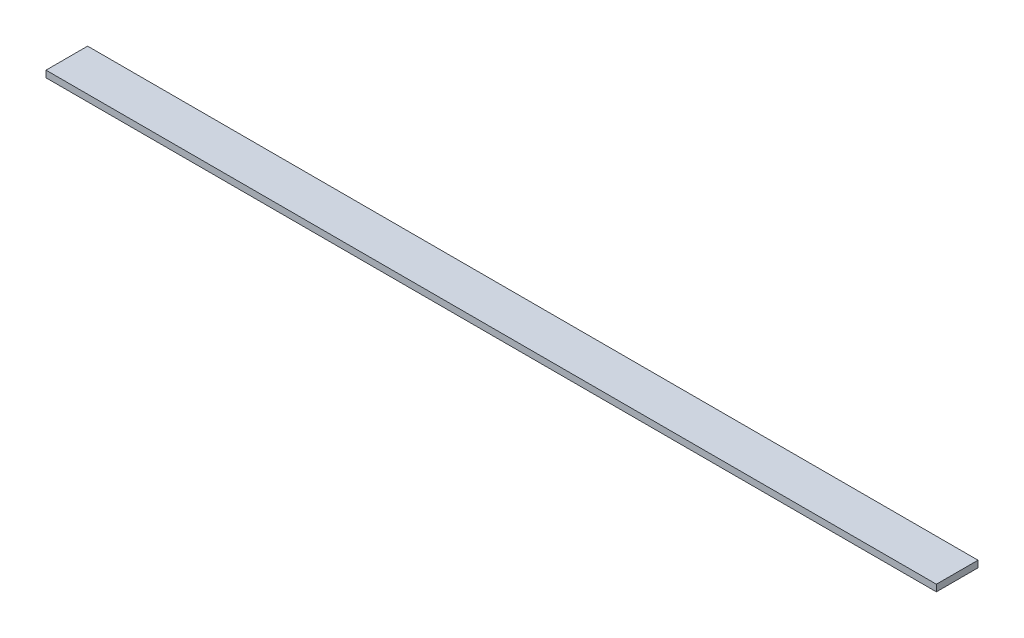
from build123d import *

# Parameters (mm, degrees)
SKETCH_1_W      = 50
SKETCH_1_H      = 8
EXTRUDE_1_DEPTH = 1070


with BuildPart() as part:
    # Эскиз1 → Бобышка-Вытянуть1 (new body)
    with BuildSketch(Plane(origin=(0, 0, 0), x_dir=(0, 0, -1), z_dir=(1, 0, 0))):
        with Locations((0, 4)):
            Rectangle(SKETCH_1_W, SKETCH_1_H)
    extrude(amount=EXTRUDE_1_DEPTH)


solid = part.part
